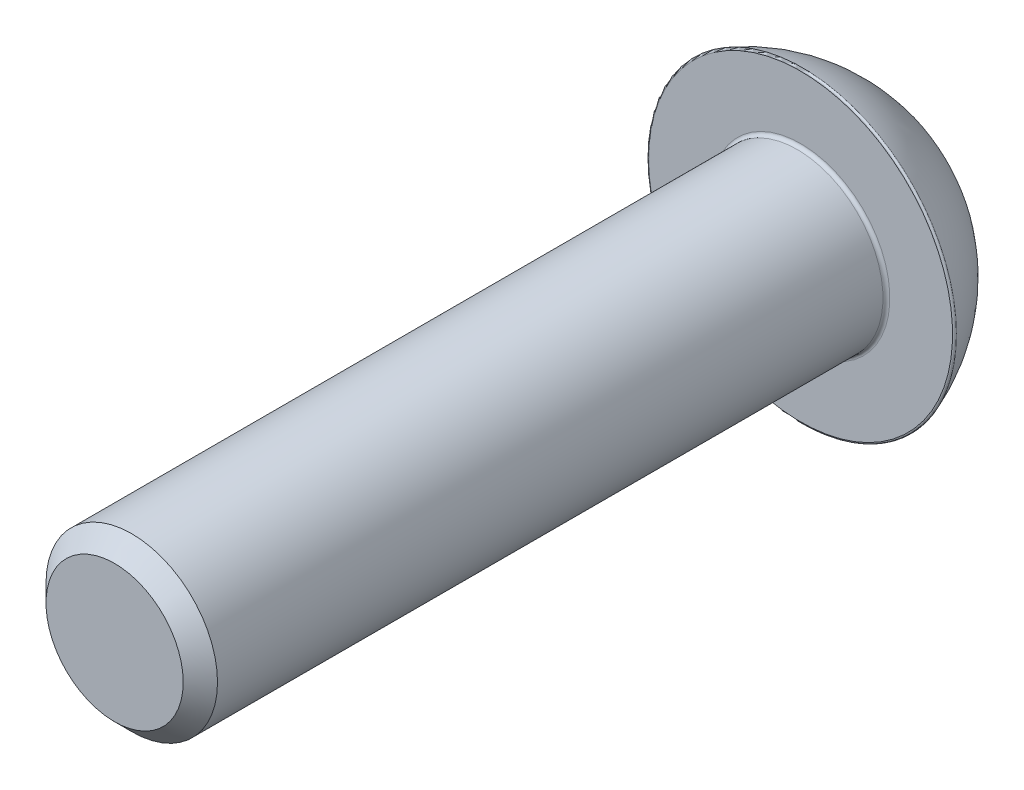
from build123d import *

# Parameters (mm, degrees)
SCHIZZO1_R                   = 2.5
ESTRUSIONE_ESTRUSIONE1_DEPTH = 20
TAGLIO_ESTRUSIONE1_DEPTH     = 2
RACCORDO1_R                  = 0.1
SMUSSO1_SIZE                 = 0.5
RACCORDO2_R                  = 0.2
RACCORDO3_R                  = 0.05


with BuildPart() as part:
    # Schizzo1 → Estrusione-Estrusione1 (new body)
    with BuildSketch(Plane.XY):
        Circle(SCHIZZO1_R)
    extrude(amount=ESTRUSIONE_ESTRUSIONE1_DEPTH)

    # Schizzo3 → Rivoluzione1 (revolve)
    with BuildSketch(Plane(origin=(0, 0, 0), x_dir=(0, 0, -1), z_dir=(1, 0, 0))):
        with BuildLine():
            Line((0, 0), (0, 4.5))
            ThreePointArc((0, 4.5), (1.41987242, 3.712340525), (2.5, 2.5))
            Line((2.5, 2.5), (2.5, 0))
            Line((2.5, 0), (0, 0))
        make_face()
    revolve(axis=Axis((0, 0, 0), (0, 0, -1)))

    # Schizzo4 → Taglio-Estrusione1 (cut)
    with BuildSketch(Plane(origin=(0, 0, -2.5), x_dir=(-1, 0, 0), z_dir=(0, 0, -1))):
        Polygon((0, 2), (-1.732050808, 1), (-1.732050808, -1), (0, -2), (1.732050808, -1), (1.732050808, 1), align=None)
    extrude(amount=-TAGLIO_ESTRUSIONE1_DEPTH, mode=Mode.SUBTRACT)

    # Schizzo5 → Taglia-Rivoluzione2 (revolve, cut)
    with BuildSketch(Plane(origin=(0, 0, 0), x_dir=(1, 0, 0), z_dir=(0, 1, 0))):
        Polygon((-2, 2.5), (-2, 2.930277164), (-1.036021703, 2.930277164), (-1.036021703, 2.25), (-1.75, 2.25), align=None)
    revolve(axis=Axis((0, 0, 0), (0, 0, -1)), mode=Mode.SUBTRACT)

    # Raccordo1
    raccordo1_edges = [part.edges().sort_by_distance(p)[0] for p in [
        (-2.5, 0, 0),
    ]]
    fillet(raccordo1_edges, radius=RACCORDO1_R)

    # Smusso1
    smusso1_edges = [part.edges().sort_by_distance(p)[0] for p in [
        (-2.5, 0, 20),
    ]]
    chamfer(smusso1_edges, length=SMUSSO1_SIZE)

    # Raccordo2
    raccordo2_edges = [part.edges().sort_by_distance(p)[0] for p in [
        (0, -2.5, -2.5),
    ]]
    fillet(raccordo2_edges, radius=RACCORDO2_R)

    # Raccordo3
    raccordo3_edges = [part.edges().sort_by_distance(p)[0] for p in [
        (0, -4.5, 0),
    ]]
    fillet(raccordo3_edges, radius=RACCORDO3_R)


solid = part.part
